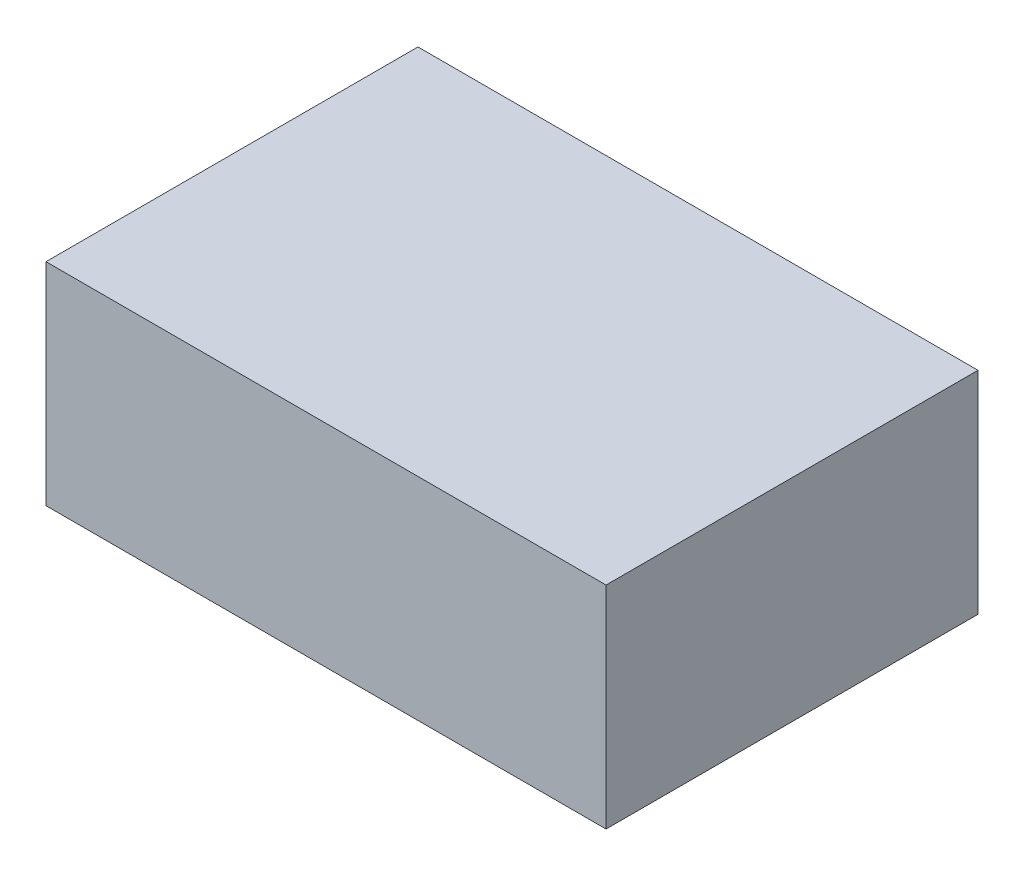
from build123d import *

# Parameters (mm, degrees)
SKETCH1_W           = 26.5
SKETCH1_H           = 17.6
BOSS_EXTRUDE1_DEPTH = 10


with BuildPart() as part:
    # Sketch1 → Boss-Extrude1 (new body)
    with BuildSketch(Plane(origin=(0, 0, 0), x_dir=(1, 0, 0), z_dir=(0, 1, 0))):
        with Locations((28.498180256, 30.933893827)):
            Rectangle(SKETCH1_W, SKETCH1_H)
    extrude(amount=BOSS_EXTRUDE1_DEPTH)


solid = part.part
